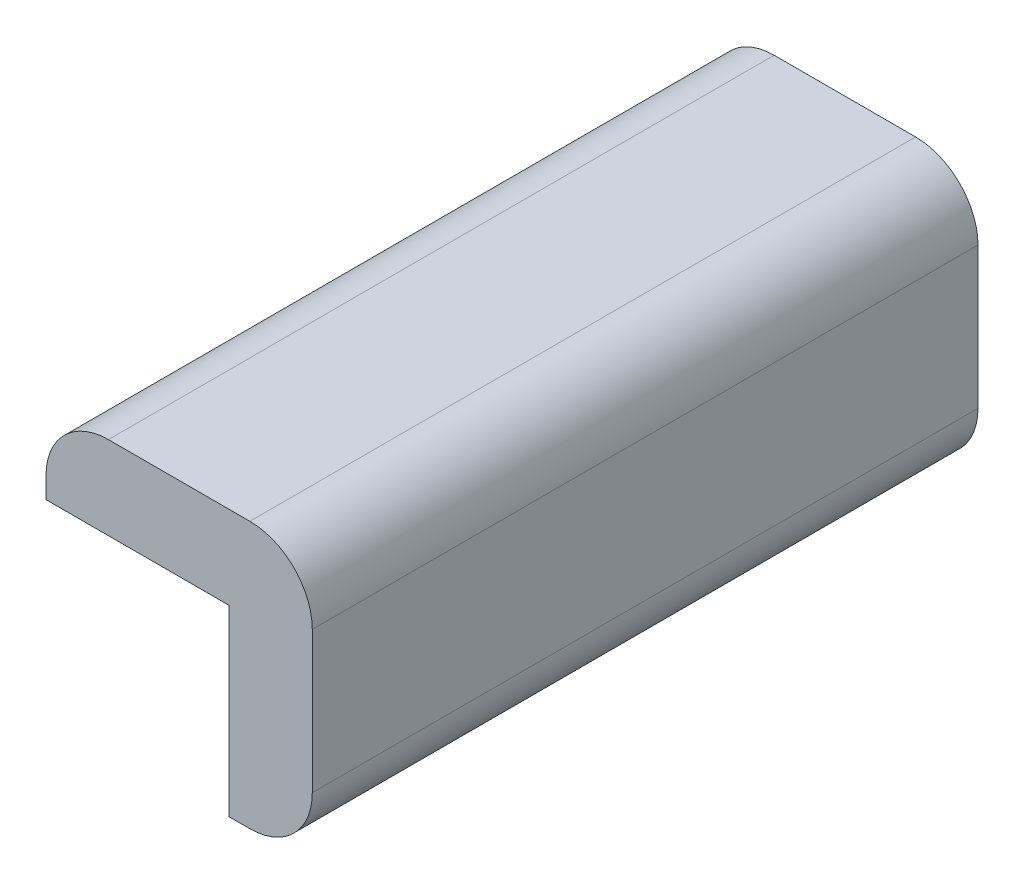
from build123d import *

# Parameters (mm, degrees)
BOSS_EXTRUDE1_DEPTH = 80


with BuildPart() as part:
    # Sketch1 → Boss-Extrude1 (new body)
    with BuildSketch(Plane.XY.offset(80)):
        with BuildLine():
            Line((-22, 24.5), (-22, 22))
            Line((-22, 22), (0, 22))
            Line((0, 22), (0, 0))
            Line((0, 0), (2.5, 0))
            ThreePointArc((2.5, 0), (7.803300859, 2.196699141), (10, 7.5))
            Line((10, 7.5), (10, 24.5))
            ThreePointArc((10, 24.5), (7.803300859, 29.803300859), (2.5, 32))
            Line((2.5, 32), (-14.5, 32))
            ThreePointArc((-14.5, 32), (-19.803300859, 29.803300859), (-22, 24.5))
        make_face()
    extrude(amount=-BOSS_EXTRUDE1_DEPTH)


solid = part.part
